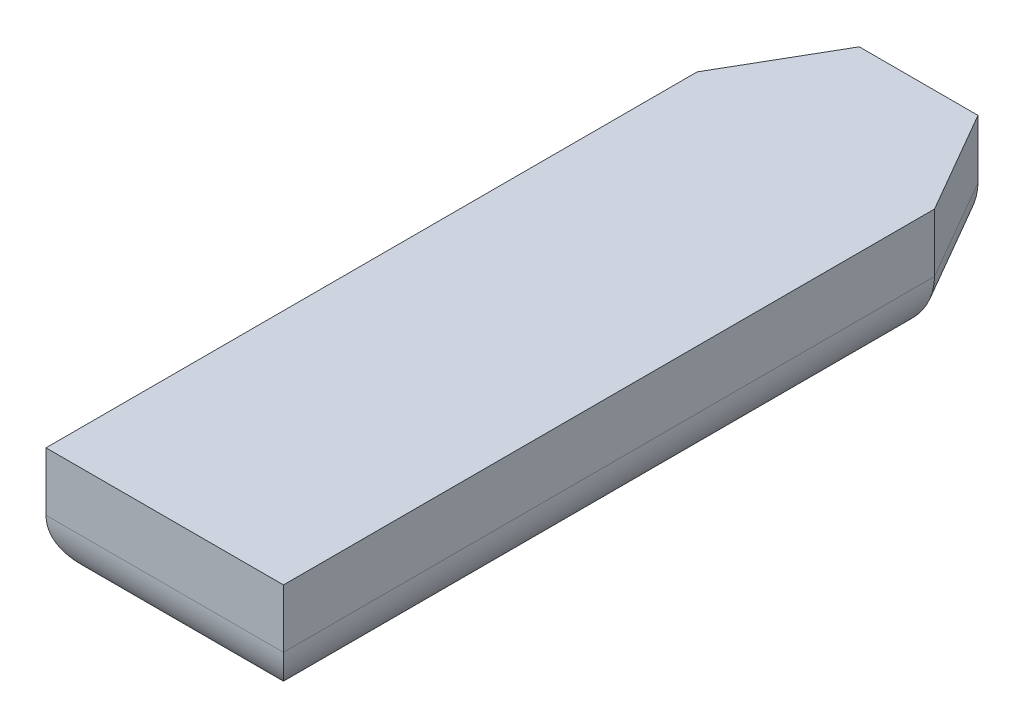
from build123d import *

# Parameters (mm, degrees)
BOSS_EXTRUDE1_DEPTH = 10
FILLET1_R           = 5.08


with BuildPart() as part:
    # Sketch1 → Boss-Extrude1 (new body)
    with BuildSketch(Plane(origin=(0, 0, 0), x_dir=(1, 0, 0), z_dir=(0, 1, 0))):
        Polygon((10, -27.419872981), (10, 27.419872981), (5, 36.080127019), (-5, 36.080127019), (-10, 27.419872981), (-10, -27.419872981), align=None)
    extrude(amount=BOSS_EXTRUDE1_DEPTH)

    # Fillet1
    fillet1_edges = [part.edges().sort_by_distance(p)[0] for p in [
        (-10, 0, 0),
        (-7.5, 0, -31.75),
        (0, 0, -36.080127019),
        (7.5, 0, -31.75),
        (10, 0, 0),
        (0, 0, 27.419872981),
    ]]
    fillet(fillet1_edges, radius=FILLET1_R)


solid = part.part
